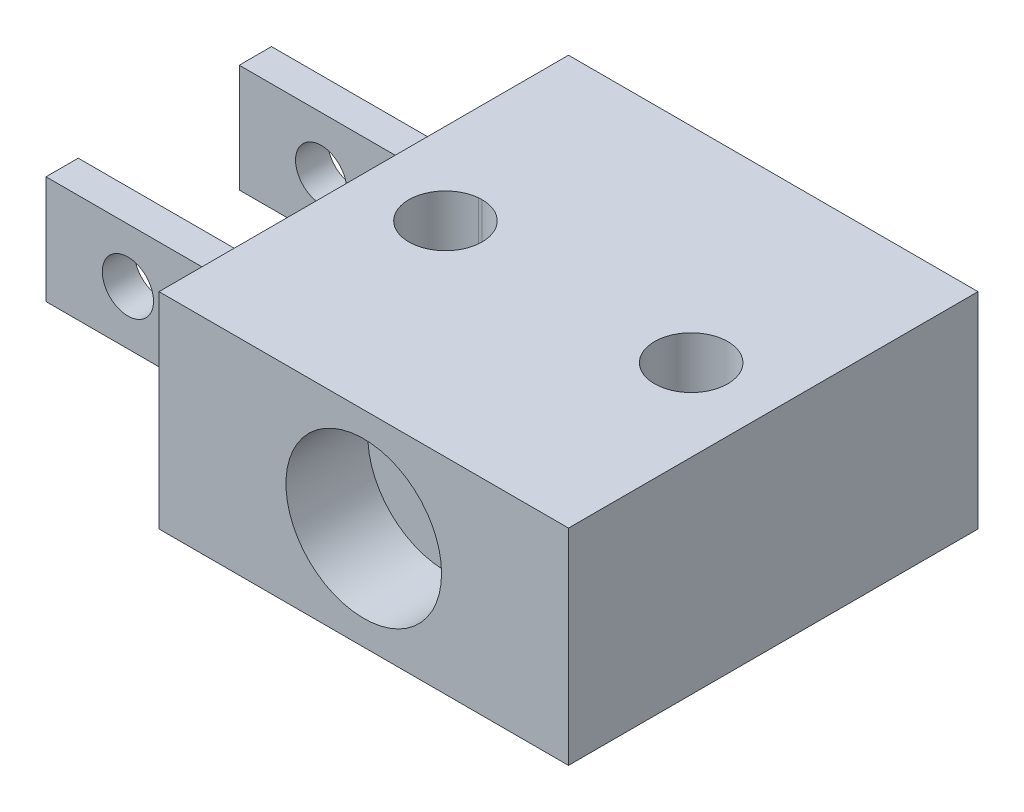
from build123d import *

# Parameters (mm, degrees)
SKETCH2_W                = 12.7
SKETCH2_H                = 12.7
BOSS_EXTRUDE4_DEPTH      = 3.6068
BOSS_EXTRUDE4_DEPTH_BACK = 2.7686
SKETCH3_W                = 1.000000006
SKETCH3_H                = 3.352800001
BOSS_EXTRUDE5_DEPTH      = 6.35
SKETCH4_R                = 0.79375
CUT_EXTRUDE1_DEPTH       = 10.854800007
SKETCH5_R                = 2.413000001
CUT_EXTRUDE2_DEPTH       = 2.54
SKETCH7_R                = 1.136382046
CUT_EXTRUDE4_DEPTH       = 7.3754


with BuildPart() as part:
    # Sketch2 → Boss-Extrude4 (new body, two sides)
    with BuildSketch(Plane(origin=(0, 0, 0), x_dir=(1, 0, 0), z_dir=(0, 1, 0))) as boss_extrude4_sk:
        with Locations((-0.031876663, -1.889989023)):
            Rectangle(SKETCH2_W, SKETCH2_H)
    extrude(amount=BOSS_EXTRUDE4_DEPTH)
    extrude(boss_extrude4_sk.sketch, amount=-BOSS_EXTRUDE4_DEPTH_BACK)

    # Sketch3 → Boss-Extrude5 (add)
    with BuildSketch(Plane.ZY.offset(6.381876663)):
        with Locations((-1.098810974, 0.417848354)):
            Rectangle(SKETCH3_W, SKETCH3_H)
        with Locations((4.894789026, 0.417848354)):
            Rectangle(SKETCH3_W, SKETCH3_H)
    extrude(amount=BOSS_EXTRUDE5_DEPTH)

    # Sketch4 → Cut-Extrude1 (cut, through all)
    with BuildSketch(Plane.XY.offset(5.394789029)):
        with Locations((-10.191876663, 0.417848354)):
            Circle(SKETCH4_R)
    extrude(amount=-CUT_EXTRUDE1_DEPTH, mode=Mode.SUBTRACT)

    # Sketch5 → Cut-Extrude2 (cut)
    with BuildSketch(Plane.XY.offset(8.239989023)):
        with Locations((-0.031876663, 0.417848354)):
            Circle(SKETCH5_R)
    extrude(amount=-CUT_EXTRUDE2_DEPTH, mode=Mode.SUBTRACT)

    # Sketch7 → Cut-Extrude4 (cut, through all)
    with BuildSketch(Plane(origin=(0, 3.6068, 0), x_dir=(1, 0, 0), z_dir=(0, 1, 0))):
        with Locations((-3.841876663, -1.89607107)):
            Circle(SKETCH7_R)
        with Locations((3.778123337, -1.89607107)):
            Circle(SKETCH7_R)
    extrude(amount=-CUT_EXTRUDE4_DEPTH, mode=Mode.SUBTRACT)


solid = part.part
